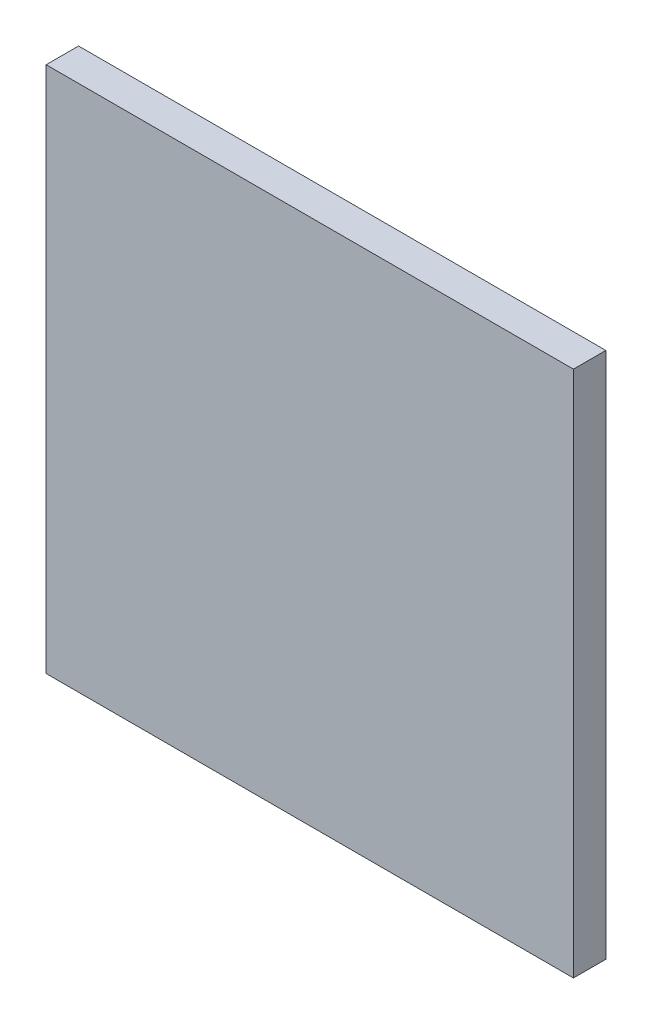
from build123d import *

# Parameters (mm, degrees)
SKETCH2_W           = 48.81
SKETCH2_H           = 48.81
BOSS_EXTRUDE1_DEPTH = 3


with BuildPart() as part:
    # Sketch2 → Boss-Extrude1 (new body)
    with BuildSketch(Plane.XY):
        Rectangle(SKETCH2_W, SKETCH2_H)
    extrude(amount=BOSS_EXTRUDE1_DEPTH)


solid = part.part
